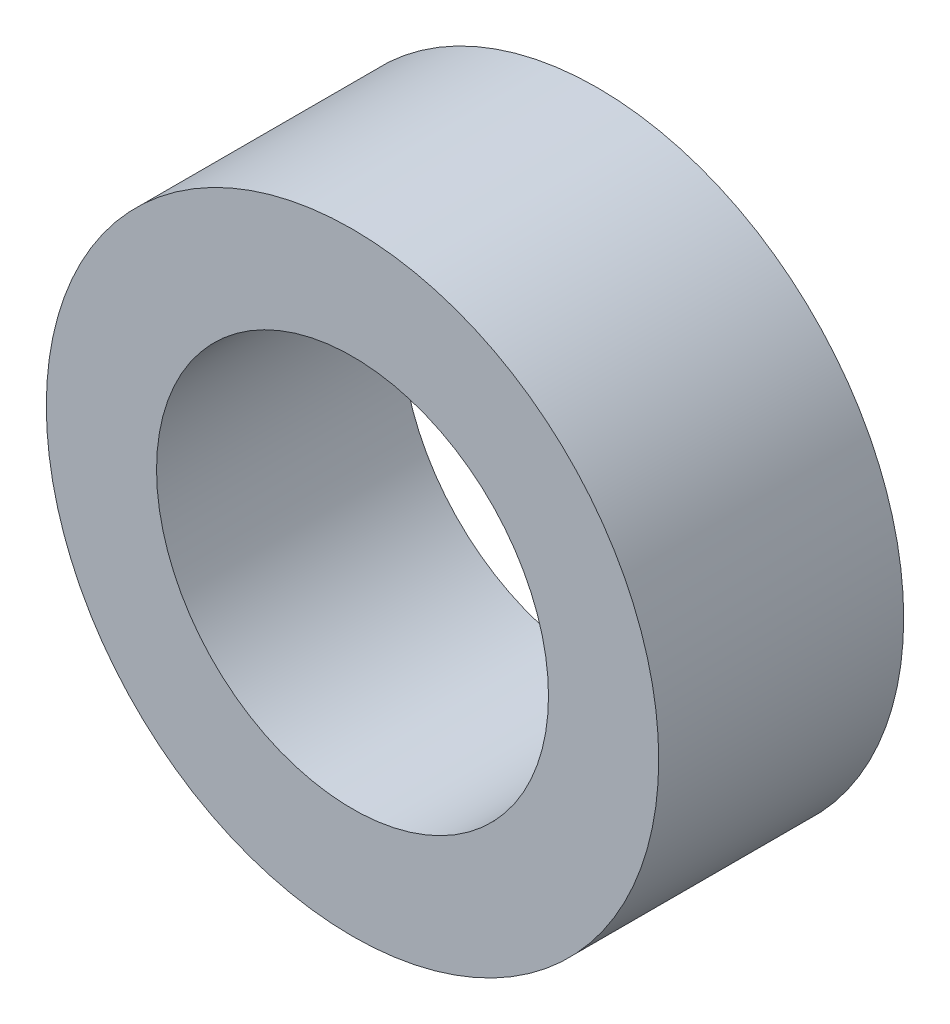
from build123d import *

# Parameters (mm, degrees)
SKETCH1_R           = 5
SKETCH1_R_2         = 3.2
BOSS_EXTRUDE1_DEPTH = 4


with BuildPart() as part:
    # Sketch1 → Boss-Extrude1 (new body)
    with BuildSketch(Plane.XY):
        Circle(SKETCH1_R)
        Circle(SKETCH1_R_2, mode=Mode.SUBTRACT)
    extrude(amount=BOSS_EXTRUDE1_DEPTH)


solid = part.part
